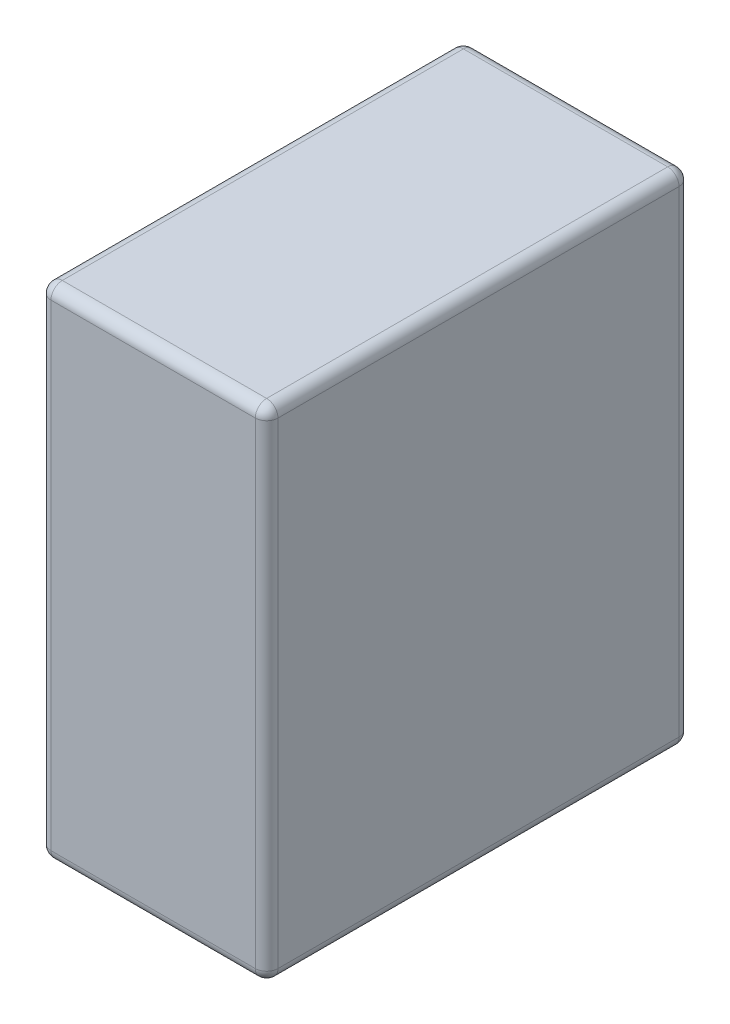
from build123d import *

# Parameters (mm, degrees)
CROQUIS1_W              = 30
CROQUIS1_H              = 56
SALIENTE_EXTRUIR1_DEPTH = 66
REDONDEO1_R             = 1.5


with BuildPart() as part:
    # Croquis1 → Saliente-Extruir1 (new body)
    with BuildSketch(Plane(origin=(0, 0, 0), x_dir=(1, 0, 0), z_dir=(0, 1, 0))):
        Rectangle(CROQUIS1_W, CROQUIS1_H)
    extrude(amount=SALIENTE_EXTRUIR1_DEPTH)

    # Redondeo1
    redondeo1_edges = [part.edges().sort_by_distance(p)[0] for p in [
        (15, 66, 0),
        (0, 66, -28),
        (-15, 66, 0),
        (0, 0, -28),
        (15, 0, 0),
        (0, 0, 28),
        (-15, 0, 0),
        (-15, 33, -28),
        (15, 33, -28),
        (15, 33, 28),
        (-15, 33, 28),
        (0, 66, 28),
    ]]
    fillet(redondeo1_edges, radius=REDONDEO1_R)


solid = part.part
